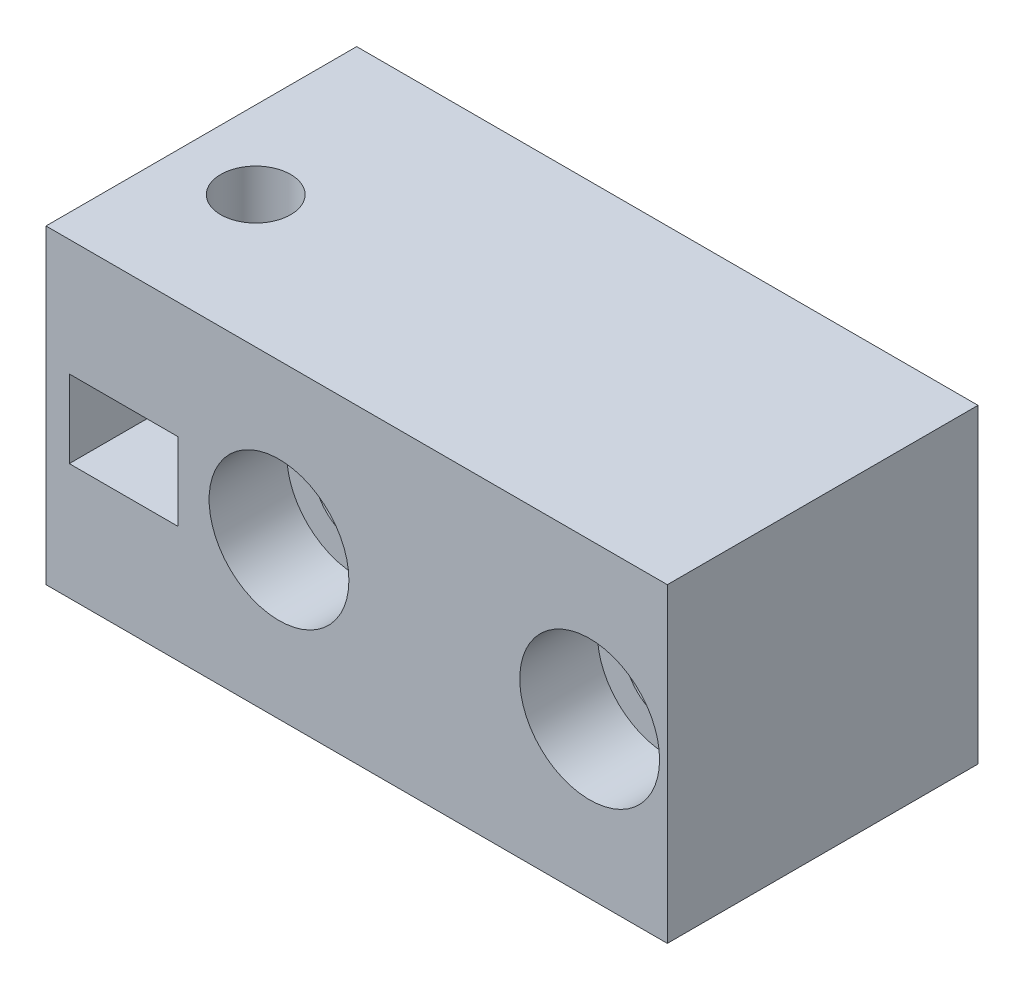
from build123d import *

# Parameters (mm, degrees)
SKETCH1_W           = 50
SKETCH1_H           = 20
BOSS_EXTRUDE1_DEPTH = 20
SKETCH2_R           = 2.75
SKETCH2_W           = 7
SKETCH2_H           = 5
CUT_EXTRUDE1_DEPTH  = 21
SKETCH3_R           = 2.25
CUT_EXTRUDE2_DEPTH  = 21
SKETCH5_W           = 8
SKETCH5_H           = 6
BOSS_EXTRUDE3_DEPTH = 3
SKETCH6_R           = 4.5
CUT_EXTRUDE3_DEPTH  = 5
SKETCH7_W           = 10
SKETCH7_H           = 20
CUT_EXTRUDE4_DEPTH  = 24


with BuildPart() as part:
    # Sketch1 → Boss-Extrude1 (new body)
    with BuildSketch(Plane.XY):
        with Locations((25, 10)):
            Rectangle(SKETCH1_W, SKETCH1_H)
    extrude(amount=BOSS_EXTRUDE1_DEPTH)

    # Sketch2 → Cut-Extrude1 (cut, through all)
    with BuildSketch(Plane.XY.offset(20)):
        with Locations((25, 10)):
            Circle(SKETCH2_R)
        with Locations((45, 10)):
            Circle(SKETCH2_R)
        with Locations((15, 10)):
            Rectangle(SKETCH2_W, SKETCH2_H)
    extrude(amount=-CUT_EXTRUDE1_DEPTH, mode=Mode.SUBTRACT)

    # Sketch3 → Cut-Extrude2 (cut, through all)
    with BuildSketch(Plane(origin=(0, 20, 0), x_dir=(1, 0, 0), z_dir=(0, 1, 0))):
        with Locations((15, -11.5)):
            Circle(SKETCH3_R)
    extrude(amount=-CUT_EXTRUDE2_DEPTH, mode=Mode.SUBTRACT)

    # Sketch5 → Boss-Extrude3 (add)
    with BuildSketch(Plane(origin=(0, 0, 0), x_dir=(-1, 0, 0), z_dir=(0, 0, -1))):
        with Locations((-35, 10)):
            Rectangle(SKETCH5_W, SKETCH5_H)
    extrude(amount=BOSS_EXTRUDE3_DEPTH)

    # Sketch6 → Cut-Extrude3 (cut)
    with BuildSketch(Plane.XY.offset(20)):
        with Locations((25, 10)):
            Circle(SKETCH6_R)
        with Locations((45, 10)):
            Circle(SKETCH6_R)
    extrude(amount=-CUT_EXTRUDE3_DEPTH, mode=Mode.SUBTRACT)

    # Sketch7 → Cut-Extrude4 (cut, through all)
    with BuildSketch(Plane.XY.offset(20)):
        with Locations((5, 10)):
            Rectangle(SKETCH7_W, SKETCH7_H)
    extrude(amount=-CUT_EXTRUDE4_DEPTH, mode=Mode.SUBTRACT)


solid = part.part
